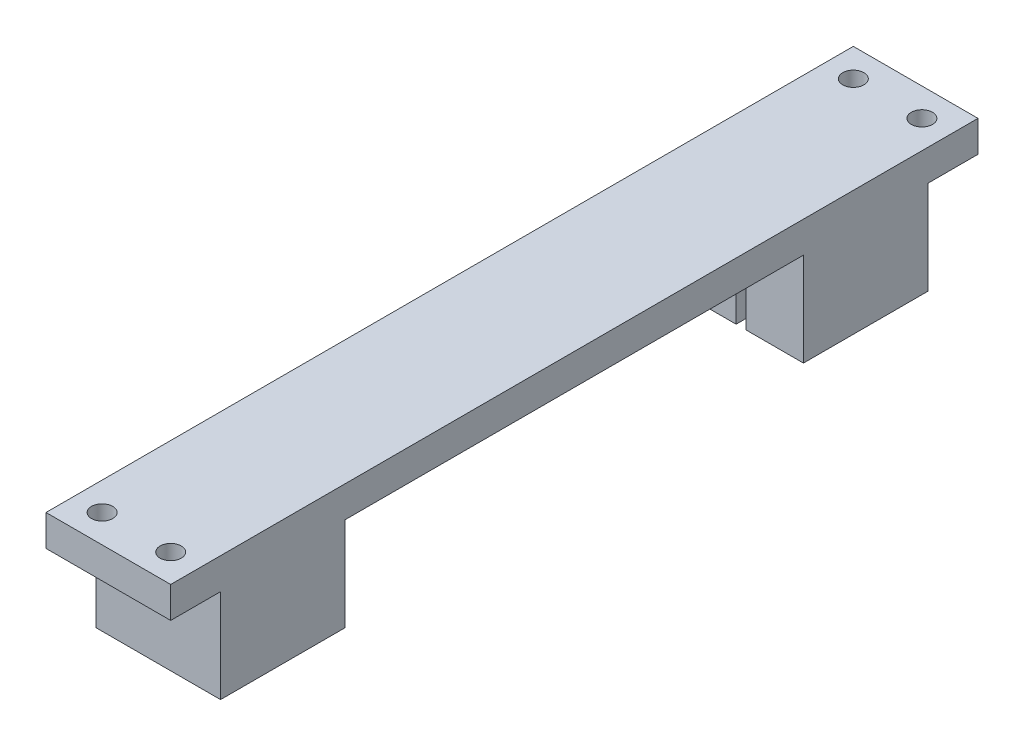
from build123d import *

# Parameters (mm, degrees)
SKETCH1_W            = 20
SKETCH1_H            = 28
BOSS_EXTRUDE1_DEPTH  = 5
SKETCH2_W            = 20
SKETCH2_H            = 20
BOSS_EXTRUDE2_DEPTH  = 15
SKETCH3_W            = 1.6
SKETCH3_H            = 7.5
CUT_EXTRUDE1_DEPTH   = 15
M3_CLEARANCE_HOLE1_D = 3.4
SKETCH6_W            = 20
SKETCH6_H            = 5
BOSS_EXTRUDE3_DEPTH  = 93.5
SKETCH7_W            = 20
SKETCH7_H            = 5
BOSS_EXTRUDE4_DEPTH  = 8
SKETCH8_W            = 20
SKETCH8_H            = 20
BOSS_EXTRUDE5_DEPTH  = 15
SKETCH9_W            = 1.6
SKETCH9_H            = 35.5
CUT_EXTRUDE2_DEPTH   = 15
M3_CLEARANCE_HOLE2_D = 3.4


with BuildPart() as part:
    # Sketch1 → Boss-Extrude1 (new body)
    with BuildSketch(Plane(origin=(0, 0, 0), x_dir=(1, 0, 0), z_dir=(0, 1, 0))):
        Rectangle(SKETCH1_W, SKETCH1_H)
    extrude(amount=BOSS_EXTRUDE1_DEPTH)

    # Sketch2 → Boss-Extrude2 (add)
    with BuildSketch(Plane(origin=(0, 0, 0), x_dir=(-1, 0, 0), z_dir=(0, -1, 0))):
        with Locations((0, 4)):
            Rectangle(SKETCH2_W, SKETCH2_H)
    extrude(amount=BOSS_EXTRUDE2_DEPTH)

    # Sketch3 → Cut-Extrude1 (cut)
    with BuildSketch(Plane(origin=(0, -15, 0), x_dir=(-1, 0, 0), z_dir=(0, -1, 0))):
        with Locations((0, 10.25)):
            Rectangle(SKETCH3_W, SKETCH3_H)
    extrude(amount=-CUT_EXTRUDE1_DEPTH, mode=Mode.SUBTRACT)

    # M3 Clearance Hole1 (through all)
    with Locations(Plane(origin=(0, 0, 0), x_dir=(-1, 0, 0), z_dir=(0, -1, 0))):
        with Locations((-5.5, -9.5), (5.5, -9.5)):
            Hole(M3_CLEARANCE_HOLE1_D / 2)

    # Sketch6 → Boss-Extrude3 (add)
    with BuildSketch(Plane(origin=(0, 0, -14), x_dir=(-1, 0, 0), z_dir=(0, 0, -1))):
        with Locations((0, 2.5)):
            Rectangle(SKETCH6_W, SKETCH6_H)
    extrude(amount=BOSS_EXTRUDE3_DEPTH)

    # Sketch7 → Boss-Extrude4 (add)
    with BuildSketch(Plane(origin=(0, 0, -107.5), x_dir=(-1, 0, 0), z_dir=(0, 0, -1))):
        with Locations((0, 2.5)):
            Rectangle(SKETCH7_W, SKETCH7_H)
    extrude(amount=BOSS_EXTRUDE4_DEPTH)

    # Sketch8 → Boss-Extrude5 (add)
    with BuildSketch(Plane(origin=(0, 0, 0), x_dir=(-1, 0, 0), z_dir=(0, -1, 0))):
        with Locations((0, 97.5)):
            Rectangle(SKETCH8_W, SKETCH8_H)
    extrude(amount=BOSS_EXTRUDE5_DEPTH)

    # Sketch9 → Cut-Extrude2 (cut)
    with BuildSketch(Plane(origin=(0, -15, 0), x_dir=(-1, 0, 0), z_dir=(0, -1, 0))):
        with Locations((0, 77.75)):
            Rectangle(SKETCH9_W, SKETCH9_H)
    extrude(amount=-CUT_EXTRUDE2_DEPTH, mode=Mode.SUBTRACT)

    # M3 Clearance Hole2 (through all)
    with Locations(Plane(origin=(0, 0, 0), x_dir=(-1, 0, 0), z_dir=(0, -1, 0))):
        with Locations((-5.5, 111), (5.5, 111)):
            Hole(M3_CLEARANCE_HOLE2_D / 2)


solid = part.part
